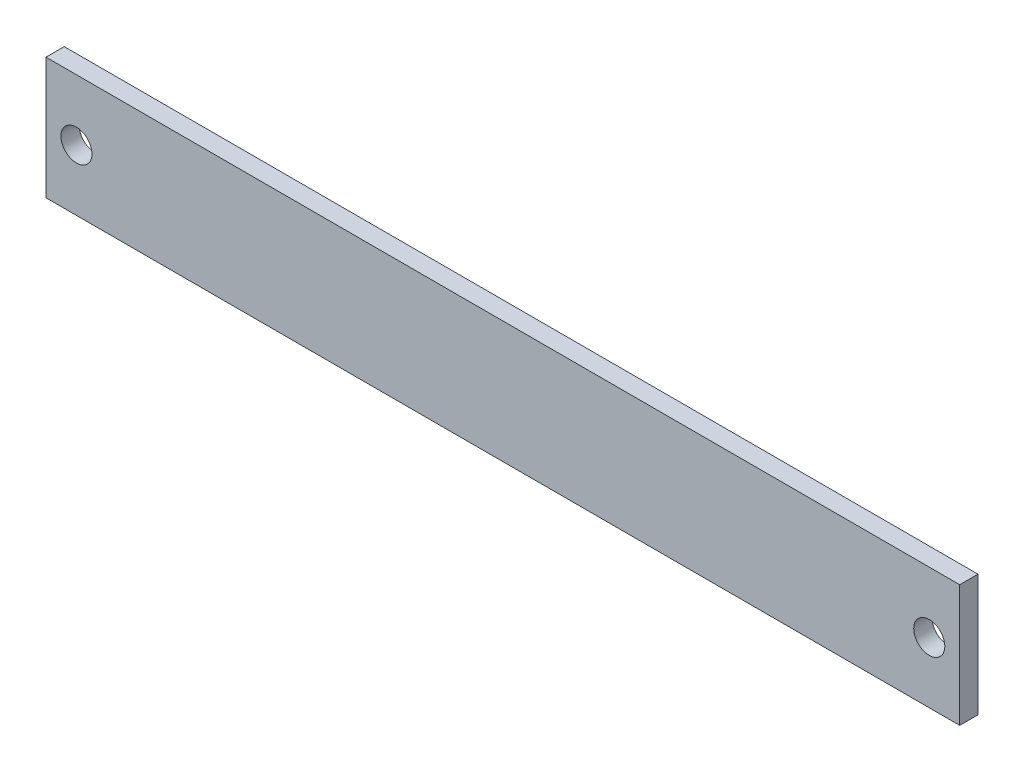
from build123d import *

# Parameters (mm, degrees)
SKETCH1_W      = 300
SKETCH1_H      = 40
SKETCH1_R      = 5.1
EXTRUDE1_DEPTH = 6


with BuildPart() as part:
    # Sketch1 → Extrude1 (new body)
    with BuildSketch(Plane.XY):
        Rectangle(SKETCH1_W, SKETCH1_H)
        with Locations((-140, 0)):
            Circle(SKETCH1_R, mode=Mode.SUBTRACT)
        with Locations((140, 0)):
            Circle(SKETCH1_R, mode=Mode.SUBTRACT)
    extrude(amount=EXTRUDE1_DEPTH)


solid = part.part
